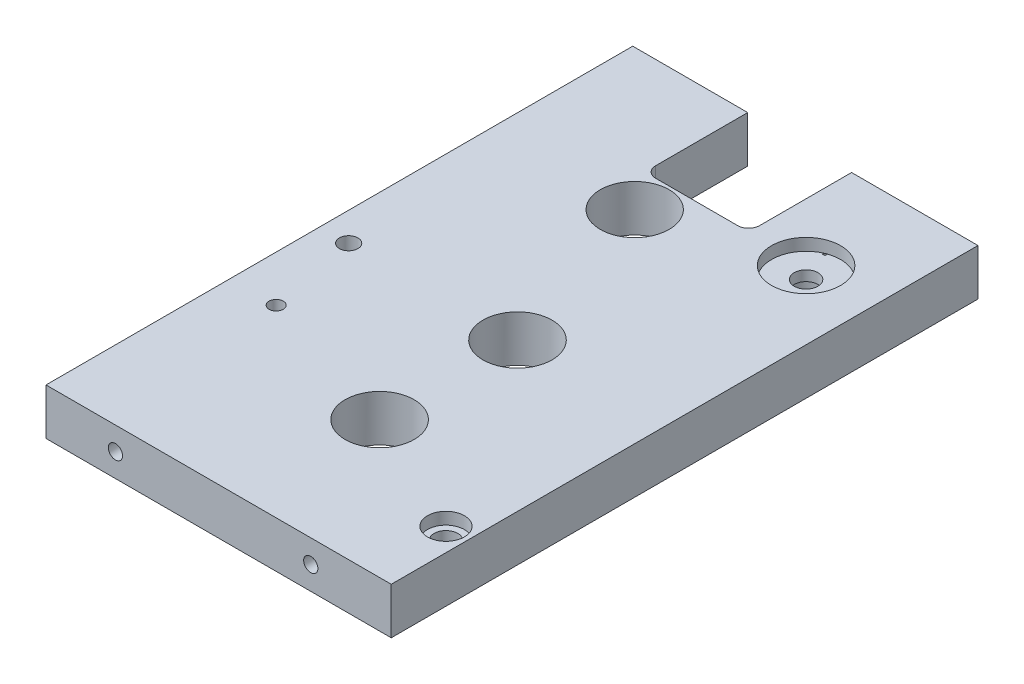
from build123d import *

# Parameters (mm, degrees)
SKETCH1_W           = 95.25
SKETCH1_H           = 12.8
BOSS_EXTRUDE1_DEPTH = 161.88
SKETCH1_3_R         = 3.1
CUT_EXTRUDE1_DEPTH  = 20.2
SKETCH1_4_R         = 2.395
CUT_EXTRUDE2_DEPTH  = 21.5
CUT_EXTRUDE3_REACH  = 369.677
SKETCH2_R           = 9.525
CUT_EXTRUDE4_REACH  = 369.677
SKETCH3_R           = 3.265
SKETCH3_R_2         = 1.96
SKETCH3_R_3         = 2.56
SKETCH4_R           = 9.525
SKETCH4_R_2         = 5.09
CUT_EXTRUDE5_DEPTH  = 3.32
SKETCH5_R           = 5.31
CUT_EXTRUDE6_DEPTH  = 6.65
SKETCH6_R           = 1.965
CUT_EXTRUDE7_DEPTH  = 17.25
SKETCH7_R           = 1.97
CUT_EXTRUDE8_DEPTH  = 15.87
SKETCH9_R           = 9.5
CUT_EXTRUDE9_DEPTH  = 368.677154617


with BuildPart() as part:
    # Sketch1 → Boss-Extrude1 (new body)
    with BuildSketch(Plane.XY):
        with Locations((-282.25, -616.5)):
            Rectangle(SKETCH1_W, SKETCH1_H)
    extrude(amount=BOSS_EXTRUDE1_DEPTH)

    # Sketch1_3 → Cut-Extrude1 (cut)
    with BuildSketch(Plane.XY):
        with Locations((-257, -616.5)):
            Circle(SKETCH1_3_R)
        with Locations((-307.5, -616.5)):
            Circle(SKETCH1_3_R)
    extrude(amount=CUT_EXTRUDE1_DEPTH, mode=Mode.SUBTRACT)

    # Sketch1_4 → Cut-Extrude2 (cut)
    with BuildSketch(Plane.XY):
        with Locations((-244.2, -616.5)):
            Circle(SKETCH1_4_R)
        with Locations((-320.5, -616.5)):
            Circle(SKETCH1_4_R)
    extrude(amount=CUT_EXTRUDE2_DEPTH, mode=Mode.SUBTRACT)

    # Sketch2 → Cut-Extrude3 (cut, up to next)
    with BuildSketch(Plane(origin=(0, -610.1, 0), x_dir=(1, 0, 0), z_dir=(0, 1, 0)), mode=Mode.PRIVATE) as cut_extrude3_sk1:
        with Locations((-275.57, -124.135)):
            Circle(SKETCH2_R)
    cut_extrude3_tool1 = extrude(cut_extrude3_sk1.sketch, amount=-CUT_EXTRUDE3_REACH, mode=Mode.PRIVATE) & part.part
    # Sketch2 → Cut-Extrude3 (cut, up to next)
    with BuildSketch(Plane(origin=(0, -610.1, 0), x_dir=(1, 0, 0), z_dir=(0, 1, 0)), mode=Mode.PRIVATE) as cut_extrude3_sk2:
        with Locations((-275.57, -86.105)):
            Circle(SKETCH2_R)
    cut_extrude3_tool2 = extrude(cut_extrude3_sk2.sketch, amount=-CUT_EXTRUDE3_REACH, mode=Mode.PRIVATE) & part.part
    # Sketch2 → Cut-Extrude3 (cut, up to next)
    with BuildSketch(Plane(origin=(0, -610.1, 0), x_dir=(1, 0, 0), z_dir=(0, 1, 0)), mode=Mode.PRIVATE) as cut_extrude3_sk3:
        with BuildLine():
            Line((-269.505, 0), (-298.155, 0))
            Line((-298.155, 0), (-298.155, -25.4))
            ThreePointArc((-298.155, -25.4), (-297.276320344, -27.521320344), (-295.155, -28.4))
            Line((-295.155, -28.4), (-272.505, -28.4))
            ThreePointArc((-272.505, -28.4), (-270.383679656, -27.521320344), (-269.505, -25.4))
            Line((-269.505, -25.4), (-269.505, 0))
        make_face()
    cut_extrude3_tool3 = extrude(cut_extrude3_sk3.sketch, amount=-CUT_EXTRUDE3_REACH, mode=Mode.PRIVATE) & part.part
    add(cut_extrude3_tool1.solids().sort_by_distance((-275.57, -610.1, 124.135))[0], mode=Mode.SUBTRACT)
    add(cut_extrude3_tool2.solids().sort_by_distance((-275.57, -610.1, 86.105))[0], mode=Mode.SUBTRACT)
    add(cut_extrude3_tool3.solids().sort_by_distance((-283.83, -610.1, 14.135461))[0], mode=Mode.SUBTRACT)

    # Sketch3 → Cut-Extrude4 (cut, up to next)
    with BuildSketch(Plane(origin=(0, -610.1, 0), x_dir=(-1, 0, 0), z_dir=(0, 1, 0)), mode=Mode.PRIVATE) as cut_extrude4_sk1:
        with Locations((240.925, 140.49)):
            Circle(SKETCH3_R)
    cut_extrude4_tool1 = extrude(cut_extrude4_sk1.sketch, amount=-CUT_EXTRUDE4_REACH, mode=Mode.PRIVATE) & part.part
    # Sketch3 → Cut-Extrude4 (cut, up to next)
    with BuildSketch(Plane(origin=(0, -610.1, 0), x_dir=(-1, 0, 0), z_dir=(0, 1, 0)), mode=Mode.PRIVATE) as cut_extrude4_sk2:
        with Locations((253.55, 28.505)):
            Circle(SKETCH3_R)
    cut_extrude4_tool2 = extrude(cut_extrude4_sk2.sketch, amount=-CUT_EXTRUDE4_REACH, mode=Mode.PRIVATE) & part.part
    # Sketch3 → Cut-Extrude4 (cut, up to next)
    with BuildSketch(Plane(origin=(0, -610.1, 0), x_dir=(-1, 0, 0), z_dir=(0, 1, 0)), mode=Mode.PRIVATE) as cut_extrude4_sk3:
        with Locations((317.175, 111.08)):
            Circle(SKETCH3_R_2)
    cut_extrude4_tool3 = extrude(cut_extrude4_sk3.sketch, amount=-CUT_EXTRUDE4_REACH, mode=Mode.PRIVATE) & part.part
    # Sketch3 → Cut-Extrude4 (cut, up to next)
    with BuildSketch(Plane(origin=(0, -610.1, 0), x_dir=(-1, 0, 0), z_dir=(0, 1, 0)), mode=Mode.PRIVATE) as cut_extrude4_sk4:
        with Locations((321.975, 86.28)):
            Circle(SKETCH3_R_3)
    cut_extrude4_tool4 = extrude(cut_extrude4_sk4.sketch, amount=-CUT_EXTRUDE4_REACH, mode=Mode.PRIVATE) & part.part
    add(cut_extrude4_tool1.solids().sort_by_distance((-240.925, -610.1, 140.49))[0], mode=Mode.SUBTRACT)
    add(cut_extrude4_tool2.solids().sort_by_distance((-253.55, -610.1, 28.505))[0], mode=Mode.SUBTRACT)
    add(cut_extrude4_tool3.solids().sort_by_distance((-317.175, -610.1, 111.08))[0], mode=Mode.SUBTRACT)
    add(cut_extrude4_tool4.solids().sort_by_distance((-321.975, -610.1, 86.28))[0], mode=Mode.SUBTRACT)

    # Sketch4 → Cut-Extrude5 (cut)
    with BuildSketch(Plane(origin=(0, -610.1, 0), x_dir=(-1, 0, 0), z_dir=(0, 1, 0))):
        with Locations((253.55, 28.505)):
            Circle(SKETCH4_R)
        with Locations((240.925, 140.49)):
            Circle(SKETCH4_R_2)
    extrude(amount=-CUT_EXTRUDE5_DEPTH, mode=Mode.SUBTRACT)

    # Sketch5 → Cut-Extrude6 (cut)
    with BuildSketch(Plane.XZ.offset(622.9)):
        with Locations((-240.925, 140.49)):
            Circle(SKETCH5_R)
        with Locations((-253.55, 28.505)):
            Circle(SKETCH5_R)
    extrude(amount=-CUT_EXTRUDE6_DEPTH, mode=Mode.SUBTRACT)

    # Sketch6 → Cut-Extrude7 (cut)
    with BuildSketch(Plane.XY.offset(161.88)):
        with Locations((-310.715, -616.48)):
            Circle(SKETCH6_R)
        with Locations((-256.825, -616.48)):
            Circle(SKETCH6_R)
    extrude(amount=-CUT_EXTRUDE7_DEPTH, mode=Mode.SUBTRACT)

    # Sketch7 → Cut-Extrude8 (cut)
    with BuildSketch(Plane.ZY.offset(329.875)):
        with Locations((142.28, -616.5)):
            Circle(SKETCH7_R)
    extrude(amount=-CUT_EXTRUDE8_DEPTH, mode=Mode.SUBTRACT)

    # Sketch9 → Cut-Extrude9 (cut, through all)
    with BuildSketch(Plane.XZ.offset(622.9)):
        with Locations((-290.57, 38.77)):
            Circle(SKETCH9_R)
    extrude(amount=-CUT_EXTRUDE9_DEPTH, mode=Mode.SUBTRACT)


solid = part.part
